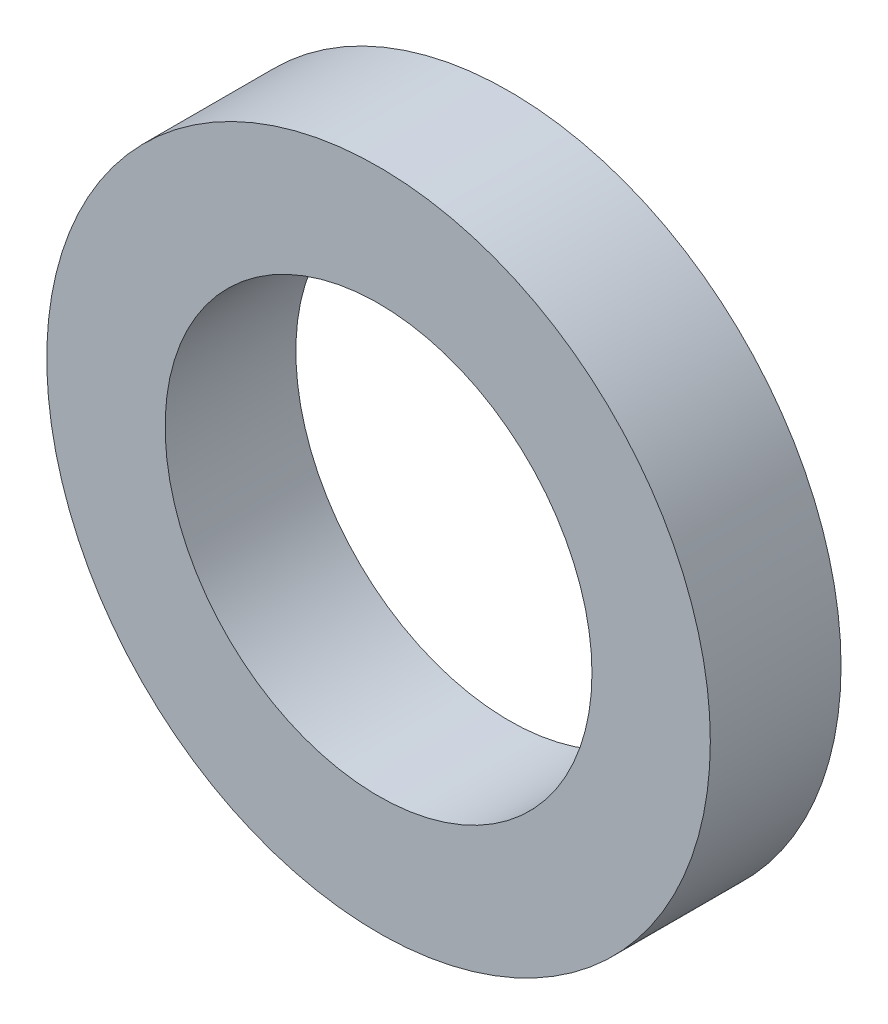
from build123d import *

# Parameters (mm, degrees)
SKETCH1_R           = 35.4584
SKETCH1_R_2         = 22.8092
BOSS_EXTRUDE1_DEPTH = 13.97


with BuildPart() as part:
    # Sketch1 → Boss-Extrude1 (new body)
    with BuildSketch(Plane.XY):
        with Locations((164.799803954, 1350.513952992)):
            Circle(SKETCH1_R)
        with Locations((164.799803954, 1350.513952992)):
            Circle(SKETCH1_R_2, mode=Mode.SUBTRACT)
    extrude(amount=BOSS_EXTRUDE1_DEPTH)


solid = part.part
